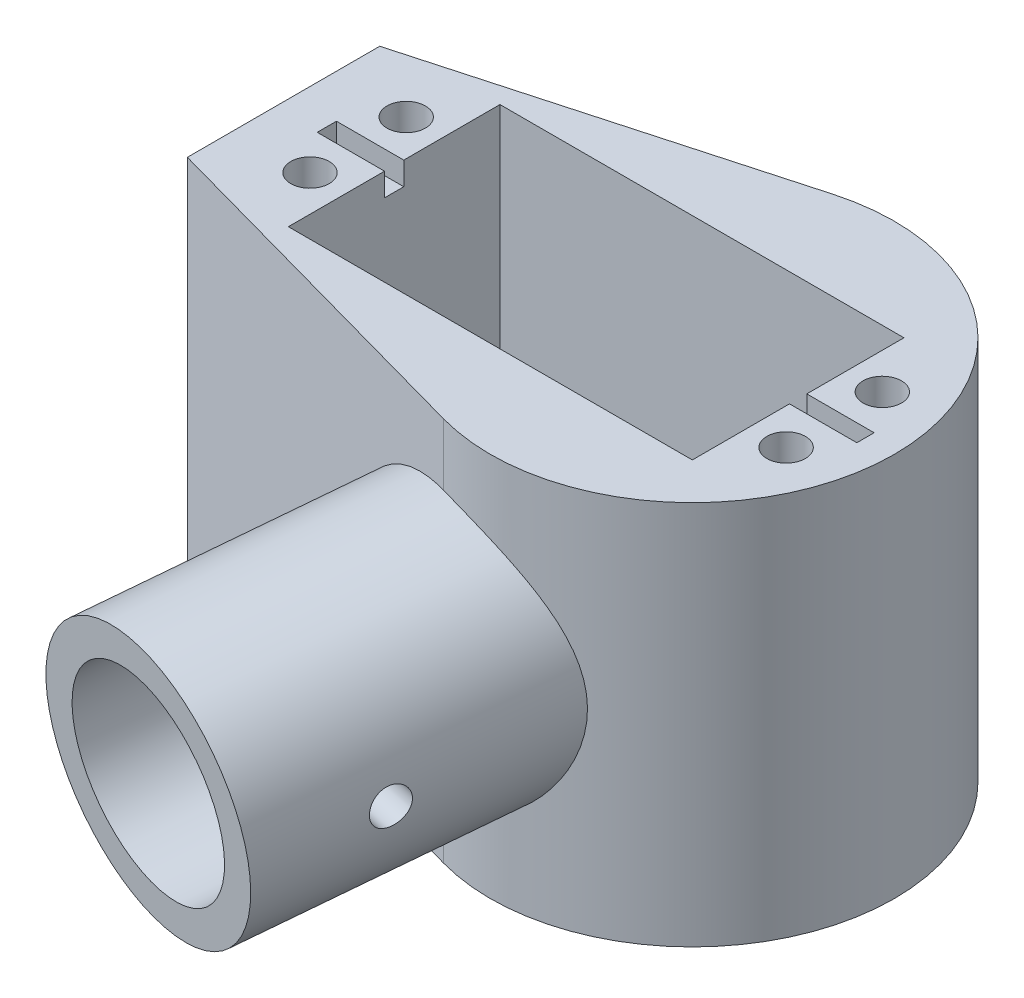
from build123d import *

# Parameters (mm, degrees)
SKETCH1_R           = 6
BOSS_EXTRUDE1_DEPTH = 40
SKETCH2_W           = 42
SKETCH2_H           = 22
CUT_EXTRUDE1_DEPTH  = 25
SKETCH3_R           = 2
CUT_EXTRUDE2_DEPTH  = 12
SKETCH4_R           = 9.5
CUT_EXTRUDE3_DEPTH  = 5
CUT_EXTRUDE4_START  = -6
SKETCH5_R           = 9.5
CUT_EXTRUDE4_DEPTH  = 6
SKETCH7_W           = 7
SKETCH7_H           = 2
SKETCH7_H_2         = 1.8
CUT_EXTRUDE5_DEPTH  = 2.4
BOSS_EXTRUDE2_REACH = 87.524
SKETCH9_R           = 13.5
SKETCH9_R_2         = 10.05
BOSS_EXTRUDE3_REACH = 71.909
SKETCH10_R          = 10.05
SKETCH11_R          = 1.9
CUT_EXTRUDE7_DEPTH  = 13.5


with BuildPart() as part:
    # Sketch1 → Boss-Extrude1 (new body)
    with BuildSketch(Plane(origin=(0, 0, 0), x_dir=(1, 0, 0), z_dir=(0, 1, 0))):
        with BuildLine():
            Line((-42.5, -10), (-5.61521172, -20.235350191))
            ThreePointArc((-5.61521172, -20.235350191), (21, 0), (-5.61521172, 20.235350191))
            Line((-5.61521172, 20.235350191), (-42.5, 10))
            Line((-42.5, 10), (-42.5, -10))
        make_face()
        Circle(SKETCH1_R, mode=Mode.SUBTRACT)
    extrude(amount=BOSS_EXTRUDE1_DEPTH)

    # Sketch2 → Cut-Extrude1 (cut)
    with BuildSketch(Plane(origin=(0, 40, 0), x_dir=(1, 0, 0), z_dir=(0, 1, 0))):
        with Locations((-10, 0)):
            Rectangle(SKETCH2_W, SKETCH2_H)
    extrude(amount=-CUT_EXTRUDE1_DEPTH, mode=Mode.SUBTRACT)

    # Sketch3 → Cut-Extrude2 (cut)
    with BuildSketch(Plane(origin=(0, 40, 0), x_dir=(1, 0, 0), z_dir=(0, 1, 0))):
        with Locations((14.75, 5)):
            Circle(SKETCH3_R)
        with Locations((14.75, -5)):
            Circle(SKETCH3_R)
        with Locations((-34.75, 5)):
            Circle(SKETCH3_R)
        with Locations((-34.75, -5)):
            Circle(SKETCH3_R)
    extrude(amount=-CUT_EXTRUDE2_DEPTH, mode=Mode.SUBTRACT)

    # Sketch4 → Cut-Extrude3 (cut)
    with BuildSketch(Plane(origin=(0, 15, 0), x_dir=(1, 0, 0), z_dir=(0, 1, 0))):
        Circle(SKETCH4_R)
    extrude(amount=-CUT_EXTRUDE3_DEPTH, mode=Mode.SUBTRACT)

    # Sketch5 → Cut-Extrude4 (cut)
    with BuildSketch(Plane.XZ.offset(CUT_EXTRUDE4_START)):
        Circle(SKETCH5_R)
    extrude(amount=CUT_EXTRUDE4_DEPTH, mode=Mode.SUBTRACT)

    # Sketch7 → Cut-Extrude5 (cut)
    with BuildSketch(Plane(origin=(0, 40, 0), x_dir=(1, 0, 0), z_dir=(0, 1, 0))):
        with Locations((-34.5, 0)):
            Rectangle(SKETCH7_W, SKETCH7_H)
        with Locations((14.5, 0)):
            Rectangle(SKETCH7_W, SKETCH7_H_2)
    extrude(amount=-CUT_EXTRUDE5_DEPTH, mode=Mode.SUBTRACT)

    # Sketch9 → Boss-Extrude2 (add, up to next)
    with BuildSketch(Plane(origin=(-8.961867673, -4.60437291, 43.807681948), x_dir=(0, 0.9945218953682737, 0.10452846326765038), z_dir=(0.1993679344171976, 0.10243002349202152, -0.9745565745577032)), mode=Mode.PRIVATE) as boss_extrude2_sk1:
        with Locations((22.005607966, -1.9070974)):
            Circle(SKETCH9_R)
        with Locations((22.005607966, -1.9070974)):
            Circle(SKETCH9_R_2, mode=Mode.SUBTRACT)
    boss_extrude2_tool1 = extrude(boss_extrude2_sk1.sketch, amount=BOSS_EXTRUDE2_REACH, mode=Mode.PRIVATE) - part.part
    add(boss_extrude2_tool1.solids().sort_by_distance((-10.83068, 4.27413, 44.358542))[0])

    # Sketch10 → Boss-Extrude3 (add, up to next)
    with BuildSketch(Plane(origin=(-3.977669313, -2.043622323, 19.443767584), x_dir=(0.9799247046208295, -0.020839623809475377, 0.19827577601224913), z_dir=(-0.19936793441719772, -0.10243002349202134, 0.9745565745577032)), mode=Mode.PRIVATE) as boss_extrude3_sk1:
        with Locations((-1.9070974, 22.005607966)):
            Circle(SKETCH10_R)
    boss_extrude3_tool1 = extrude(boss_extrude3_sk1.sketch, amount=-BOSS_EXTRUDE3_REACH, mode=Mode.PRIVATE) - part.part
    add(boss_extrude3_tool1.solids().sort_by_distance((-5.846481, 19.88118, 21.365849))[0])

    # Sketch11 → Cut-Extrude7 (cut, symmetric)
    with BuildSketch(Plane(origin=(-1.868811857, 0.039743192, -0.378131217), x_dir=(-0.19936793441719755, -0.10243002349202149, 0.9745565745577031), z_dir=(-0.9799247046208296, 0.02083962380947537, -0.19827577601224902))):
        with Locations((32.45139953, 22.005607966)):
            Circle(SKETCH11_R)
    extrude(amount=CUT_EXTRUDE7_DEPTH, both=True, mode=Mode.SUBTRACT)


solid = part.part
